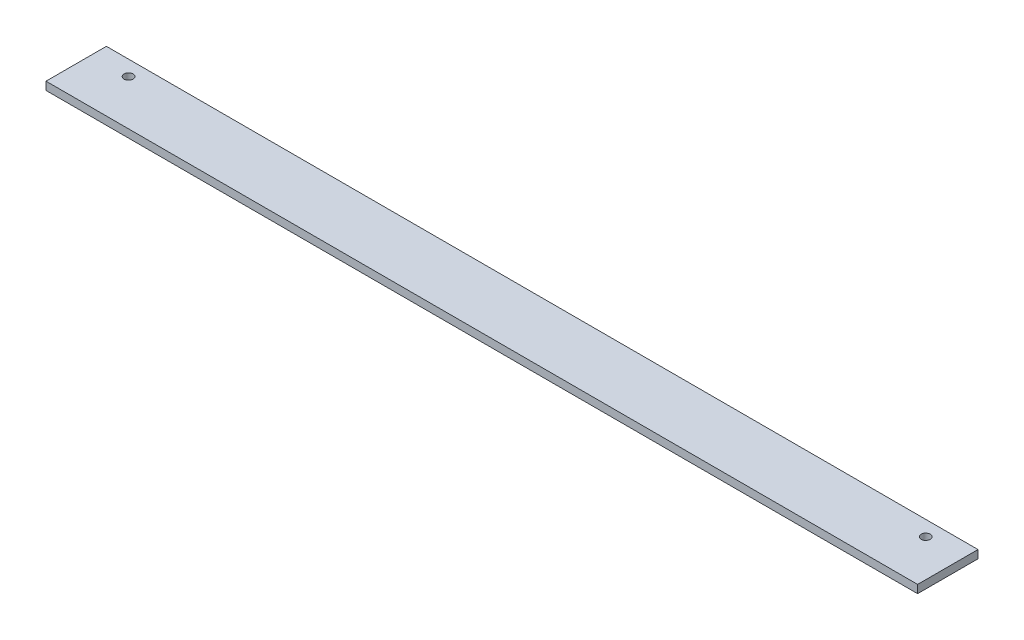
from build123d import *

# Parameters (mm, degrees)
SKETCH_1_W          = 30
SKETCH_1_H          = 4
EXTRUDE_1_DEPTH     = 433
SKETCH_2_R          = 2.25
CUT_EXTRUDE_1_DEPTH = 5


with BuildPart() as part:
    # Эскиз1 → Бобышка-Вытянуть1 (new body)
    with BuildSketch(Plane(origin=(0, 0, 0), x_dir=(0, 0, -1), z_dir=(1, 0, 0))):
        Rectangle(SKETCH_1_W, SKETCH_1_H)
    extrude(amount=EXTRUDE_1_DEPTH)

    # Эскиз2 → Вырез-Вытянуть1 (cut, through all)
    with BuildSketch(Plane(origin=(0, 2, 0), x_dir=(1, 0, 0), z_dir=(0, 1, 0))):
        with Locations((18.5, 7.5)):
            Circle(SKETCH_2_R)
        with Locations((414.5, 7.5)):
            Circle(SKETCH_2_R)
    extrude(amount=-CUT_EXTRUDE_1_DEPTH, mode=Mode.SUBTRACT)


solid = part.part
